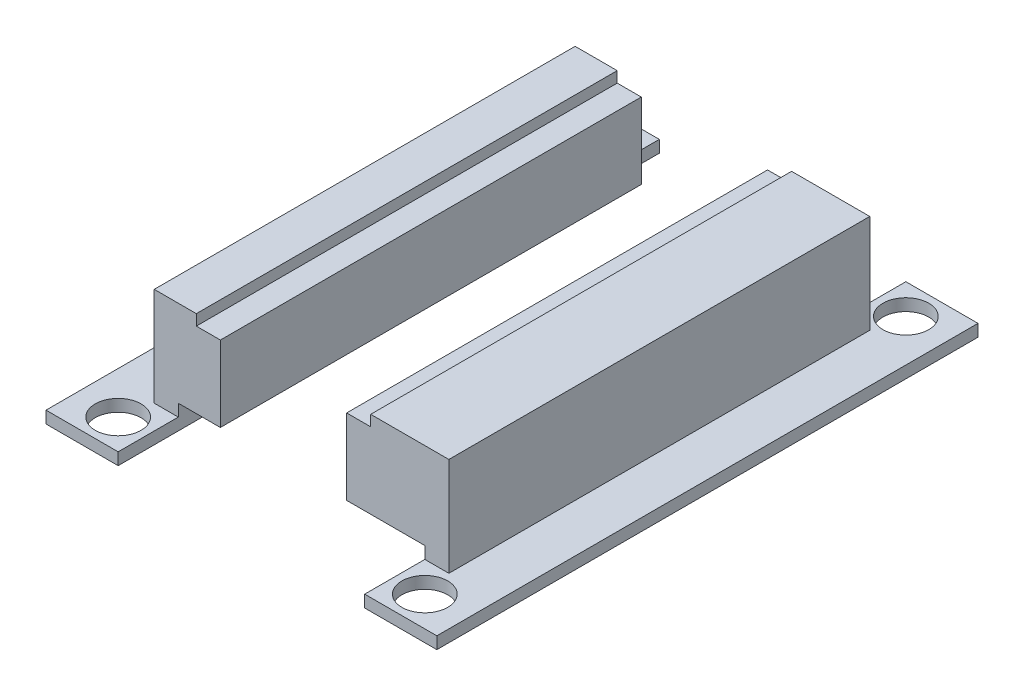
from build123d import *

# Parameters (mm, degrees)
BOSS_EXTRUDE3_DEPTH   = 45
BOSS_EXTRUDE3_2_DEPTH = 45
SKETCH4_W             = 5
SKETCH4_H             = 8.2
CUT_EXTRUDE1_DEPTH    = 29.5
SKETCH5_R             = 1.905
CUT_EXTRUDE2_DEPTH    = 2
SKETCH6_W             = 5
SKETCH6_H             = 8.2
CUT_EXTRUDE3_DEPTH    = 29.5
SKETCH7_R             = 1.905
CUT_EXTRUDE4_DEPTH    = 2


with BuildPart() as part:
    # Sketch2 → Boss-Extrude3 (new body)
    with BuildSketch(Plane.XY):
        Polygon((10.25, 0), (10.25, 2), (3.75, 2), (3.75, 8.3), (5.75, 8.3), (5.75, 9.2), (12.25, 9.2), (12.25, 1), (16.25, 1), (16.25, 0), align=None)
    extrude(amount=BOSS_EXTRUDE3_DEPTH)


with BuildPart() as body_2:
    # Sketch2 → Boss-Extrude3 2 (new body)
    with BuildSketch(Plane.XY):
        Polygon((-6.75, 8.3), (-6.75, 2), (-10.25, 2), (-10.25, 0), (-16.25, 0), (-16.25, 1), (-12.25, 1), (-12.25, 9.2), (-8.75, 9.2), (-8.75, 8.3), align=None)
    extrude(amount=BOSS_EXTRUDE3_2_DEPTH)


with BuildPart() as cut_extrude1_tool:
    # Sketch4 → Cut-Extrude1 (new body, through all)
    with BuildSketch(Plane(origin=(12.25, 0, 0), x_dir=(0, 0, -1), z_dir=(1, 0, 0))):
        with Locations((-42.5, 5.1)):
            Rectangle(SKETCH4_W, SKETCH4_H)
    extrude(amount=-CUT_EXTRUDE1_DEPTH)


with BuildPart() as part_1:
    add(part.part)

    # Cut-Extrude1: cut by cut_extrude1_tool
    add(cut_extrude1_tool.part, mode=Mode.SUBTRACT)


with BuildPart() as body_2_1:
    add(body_2.part)

    # Cut-Extrude1: cut by cut_extrude1_tool
    add(cut_extrude1_tool.part, mode=Mode.SUBTRACT)


with BuildPart() as cut_extrude2_tool:
    # Sketch5 → Cut-Extrude2 (new body, through all)
    with BuildSketch(Plane(origin=(0, 1, 0), x_dir=(1, 0, 0), z_dir=(0, 1, 0))):
        with Locations((-12.75, -42.5)):
            Circle(SKETCH5_R)
        with Locations((12.75, -42.5)):
            Circle(SKETCH5_R)
    extrude(amount=-CUT_EXTRUDE2_DEPTH)


with BuildPart() as part_2:
    add(part_1.part)

    # Cut-Extrude2: cut by cut_extrude2_tool
    add(cut_extrude2_tool.part, mode=Mode.SUBTRACT)


with BuildPart() as body_2_2:
    add(body_2_1.part)

    # Cut-Extrude2: cut by cut_extrude2_tool
    add(cut_extrude2_tool.part, mode=Mode.SUBTRACT)


with BuildPart() as cut_extrude3_tool:
    # Sketch6 → Cut-Extrude3 (new body, through all)
    with BuildSketch(Plane(origin=(12.25, 0, 0), x_dir=(0, 0, -1), z_dir=(1, 0, 0))):
        with Locations((-2.5, 5.1)):
            Rectangle(SKETCH6_W, SKETCH6_H)
    extrude(amount=-CUT_EXTRUDE3_DEPTH)


with BuildPart() as part_3:
    add(part_2.part)

    # Cut-Extrude3: cut by cut_extrude3_tool
    add(cut_extrude3_tool.part, mode=Mode.SUBTRACT)


with BuildPart() as body_2_3:
    add(body_2_2.part)

    # Cut-Extrude3: cut by cut_extrude3_tool
    add(cut_extrude3_tool.part, mode=Mode.SUBTRACT)


with BuildPart() as cut_extrude4_tool:
    # Sketch7 → Cut-Extrude4 (new body, through all)
    with BuildSketch(Plane(origin=(0, 1, 0), x_dir=(1, 0, 0), z_dir=(0, 1, 0))):
        with Locations((-12.75, -2.5)):
            Circle(SKETCH7_R)
        with Locations((12.75, -2.5)):
            Circle(SKETCH7_R)
    extrude(amount=-CUT_EXTRUDE4_DEPTH)


with BuildPart() as part_4:
    add(part_3.part)

    # Cut-Extrude4: cut by cut_extrude4_tool
    add(cut_extrude4_tool.part, mode=Mode.SUBTRACT)


with BuildPart() as body_2_4:
    add(body_2_3.part)

    # Cut-Extrude4: cut by cut_extrude4_tool
    add(cut_extrude4_tool.part, mode=Mode.SUBTRACT)


solid = Compound([part_4.part, body_2_4.part])
